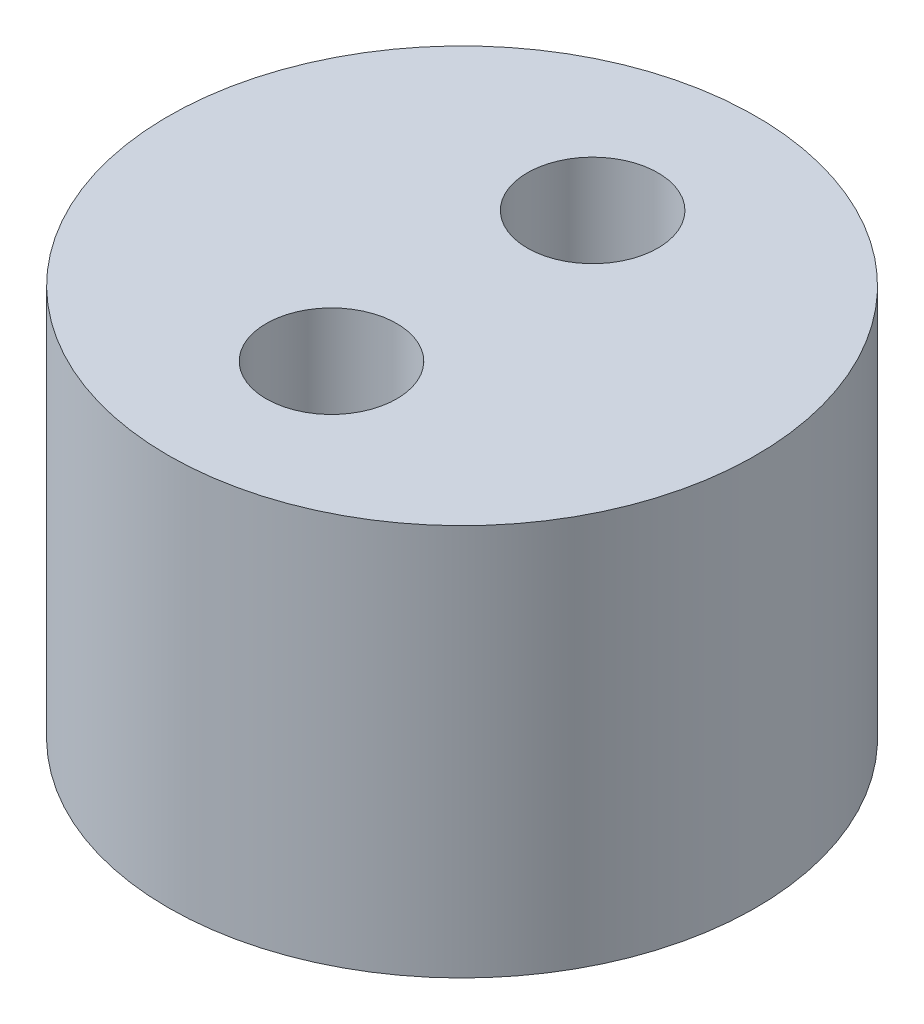
from build123d import *

# Parameters (mm, degrees)
SKETCH1_R           = 11.25
SKETCH1_R_2         = 2.5
BOSS_EXTRUDE1_DEPTH = 15


with BuildPart() as part:
    # Sketch1 → Boss-Extrude1 (new body)
    with BuildSketch(Plane(origin=(0, 0, 0), x_dir=(1, 0, 0), z_dir=(0, 1, 0))):
        Circle(SKETCH1_R)
        with Locations((0, 5)):
            Circle(SKETCH1_R_2, mode=Mode.SUBTRACT)
        with Locations((0, -5)):
            Circle(SKETCH1_R_2, mode=Mode.SUBTRACT)
    extrude(amount=BOSS_EXTRUDE1_DEPTH)


solid = part.part
